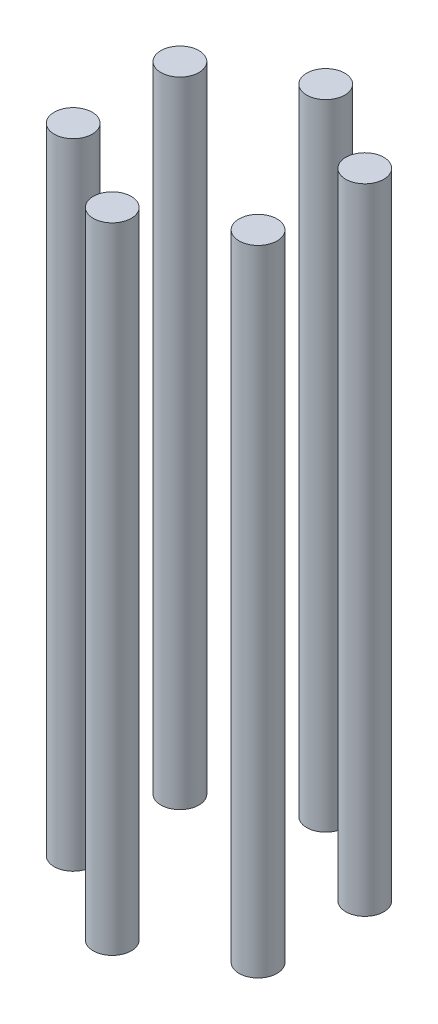
from build123d import *

# Parameters (mm, degrees)
SKETCH1_R             = 3.9
BOSS_EXTRUDE1_DEPTH   = 130
BOSS_EXTRUDE1_2_DEPTH = 130
BOSS_EXTRUDE1_3_DEPTH = 130
BOSS_EXTRUDE1_4_DEPTH = 130
BOSS_EXTRUDE1_5_DEPTH = 130
BOSS_EXTRUDE1_6_DEPTH = 130


with BuildPart() as part:
    # Sketch1 → Boss-Extrude1 (new body)
    with BuildSketch(Plane(origin=(0, 0, 0), x_dir=(1, 0, 0), z_dir=(0, 1, 0))):
        with Locations((0, -21.869969165)):
            Circle(SKETCH1_R)
    extrude(amount=BOSS_EXTRUDE1_DEPTH)


with BuildPart() as body_2:
    # Sketch1 → Boss-Extrude1 2 (new body)
    with BuildSketch(Plane(origin=(0, 0, 0), x_dir=(1, 0, 0), z_dir=(0, 1, 0))):
        with Locations((-18.939948877, -10.934984583)):
            Circle(SKETCH1_R)
    extrude(amount=BOSS_EXTRUDE1_2_DEPTH)


with BuildPart() as body_3:
    # Sketch1 → Boss-Extrude1 3 (new body)
    with BuildSketch(Plane(origin=(0, 0, 0), x_dir=(1, 0, 0), z_dir=(0, 1, 0))):
        with Locations((-18.939948877, 10.934984583)):
            Circle(SKETCH1_R)
    extrude(amount=BOSS_EXTRUDE1_3_DEPTH)


with BuildPart() as body_4:
    # Sketch1 → Boss-Extrude1 4 (new body)
    with BuildSketch(Plane(origin=(0, 0, 0), x_dir=(1, 0, 0), z_dir=(0, 1, 0))):
        with Locations((0, 21.869969165)):
            Circle(SKETCH1_R)
    extrude(amount=BOSS_EXTRUDE1_4_DEPTH)


with BuildPart() as body_5:
    # Sketch1 → Boss-Extrude1 5 (new body)
    with BuildSketch(Plane(origin=(0, 0, 0), x_dir=(1, 0, 0), z_dir=(0, 1, 0))):
        with Locations((18.939948877, 10.934984583)):
            Circle(SKETCH1_R)
    extrude(amount=BOSS_EXTRUDE1_5_DEPTH)


with BuildPart() as body_6:
    # Sketch1 → Boss-Extrude1 6 (new body)
    with BuildSketch(Plane(origin=(0, 0, 0), x_dir=(1, 0, 0), z_dir=(0, 1, 0))):
        with Locations((18.939948877, -10.934984583)):
            Circle(SKETCH1_R)
    extrude(amount=BOSS_EXTRUDE1_6_DEPTH)


solid = Compound([part.part, body_2.part, body_3.part, body_4.part, body_5.part, body_6.part])
